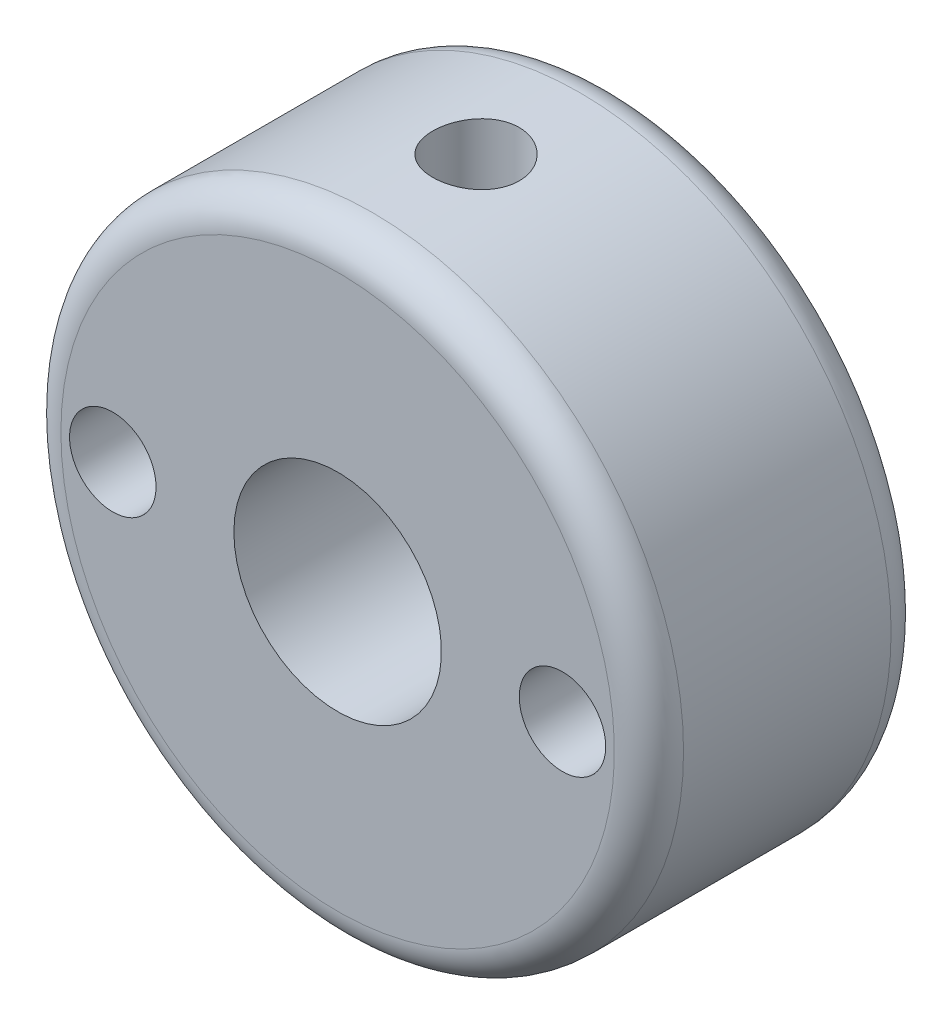
from build123d import *

# Parameters (mm, degrees)
SKETCH1_W                = 18
SKETCH1_H                = 18
BOSS_EXTRUDE1_DEPTH      = 8
M3_TAPPED_HOLE1_D        = 2.5
F_6_0_6_DIAMETER_HOLE1_D = 6
M3_TAPPED_HOLE2_REACH    = 23.656
M3_TAPPED_HOLE2_BORE_R   = 1.25
SKETCH15_R               = 12.727922061
SKETCH15_R_2             = 9
CUT_EXTRUDE1_DEPTH       = 10
FILLET1_R                = 1


with BuildPart() as part:
    # Sketch1 → Boss-Extrude1 (new body)
    with BuildSketch(Plane.XY):
        Rectangle(SKETCH1_W, SKETCH1_H)
    extrude(amount=BOSS_EXTRUDE1_DEPTH)

    # M3 Tapped Hole1 (through all)
    with Locations(Plane.XY.offset(8)):
        with Locations((6.5, 0), (-6.5, 0)):
            Hole(M3_TAPPED_HOLE1_D / 2)

    # Ø6.0 (6) Diameter Hole1 (through all)
    with Locations(Plane(origin=(0, 0, 0), x_dir=(-1, 0, 0), z_dir=(0, 0, -1))):
        with Locations((0, 0)):
            Hole(F_6_0_6_DIAMETER_HOLE1_D / 2)

    # M3 Tapped Hole2 bore → M3 Tapped Hole2 (cut, up to next)
    with BuildSketch(Plane(origin=(0, 9, 0), x_dir=(1, 0, 0), z_dir=(0, 1, 0)), mode=Mode.PRIVATE) as m3_tapped_hole2_sk1:
        with Locations((0, -4)):
            Circle(M3_TAPPED_HOLE2_BORE_R)
    m3_tapped_hole2_tool1 = extrude(m3_tapped_hole2_sk1.sketch, amount=-M3_TAPPED_HOLE2_REACH, mode=Mode.PRIVATE) & part.part
    add(m3_tapped_hole2_tool1.solids().sort_by_distance((0, 9, 4))[0], mode=Mode.SUBTRACT)

    # Sketch15 → Cut-Extrude1 (cut)
    with BuildSketch(Plane.XY.offset(8)):
        Circle(SKETCH15_R)
        Circle(SKETCH15_R_2, mode=Mode.SUBTRACT)
    extrude(amount=-CUT_EXTRUDE1_DEPTH, mode=Mode.SUBTRACT)

    # Fillet1
    fillet1_edges = [part.edges().sort_by_distance(p)[0] for p in [
        (-9, 0, 0),
        (-9, 0, 8),
    ]]
    fillet(fillet1_edges, radius=FILLET1_R)


solid = part.part
